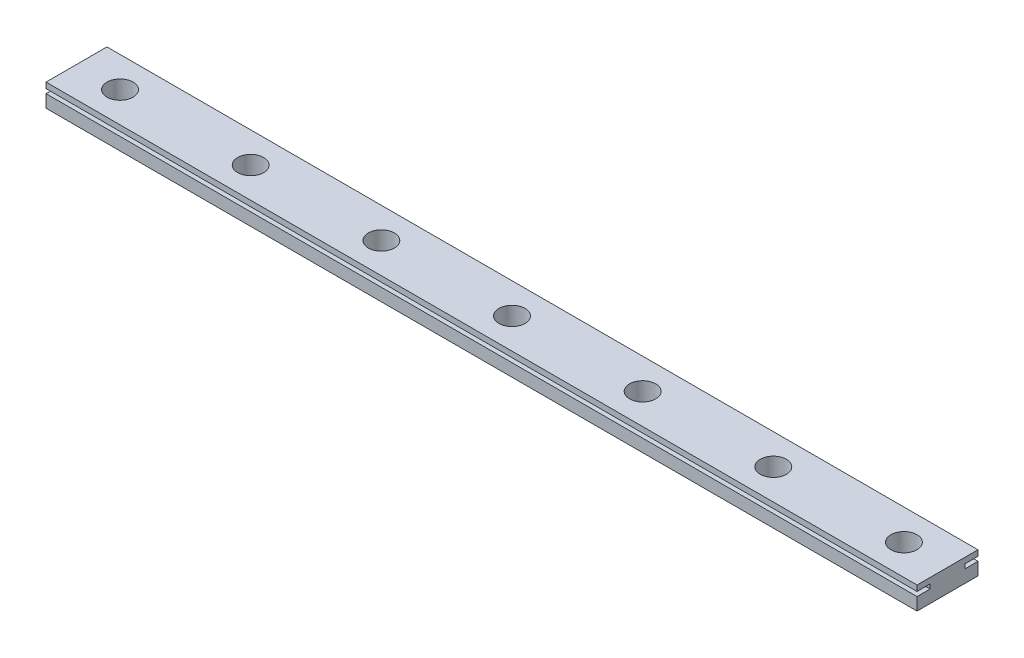
from build123d import *

# Parameters (mm, degrees)
SKETCH_1_W             = 200
SKETCH_1_H             = 14
EXTRUDE_1_DEPTH        = 5.2
SKETCH_2_W             = 3
SKETCH_2_H             = 1
CUT_EXTRUDE_1_DEPTH    = 210
SKETCH_3_R             = 1.75
CUT_EXTRUDE_2_DEPTH    = 31
SKETCH_3_3_R           = 3
SKETCH_3_3_R_2         = 1.75
CUT_EXTRUDE_3_DEPTH    = 4.5
PATTERN_LINEAR_1_COUNT = 7
PATTERN_LINEAR_1_PITCH = 30


with BuildPart() as part:
    # 草图1 → 凸台-拉伸1 (new body)
    with BuildSketch(Plane(origin=(0, 0, 0), x_dir=(1, 0, 0), z_dir=(0, 1, 0))):
        with Locations((100, 7)):
            Rectangle(SKETCH_1_W, SKETCH_1_H)
    extrude(amount=EXTRUDE_1_DEPTH)

    # 草图2 → 切除-拉伸1 (cut)
    with BuildSketch(Plane.ZY):
        with Locations((-12.5, 3.4)):
            Rectangle(SKETCH_2_W, SKETCH_2_H)
        with Locations((-1.5, 3.4)):
            Rectangle(SKETCH_2_W, SKETCH_2_H)
    extrude(amount=-CUT_EXTRUDE_1_DEPTH, mode=Mode.SUBTRACT)

    # 草图3 → 切除-拉伸2 (cut)
    with BuildSketch(Plane(origin=(0, 5.2, 0), x_dir=(1, 0, 0), z_dir=(0, 1, 0))):
        with Locations((10, 7)):
            Circle(SKETCH_3_R)
    cut_extrude_2 = extrude(amount=-CUT_EXTRUDE_2_DEPTH, mode=Mode.SUBTRACT)

    # 草图3<3> → 切除-拉伸3 (cut)
    with BuildSketch(Plane(origin=(0, 5.2, 0), x_dir=(1, 0, 0), z_dir=(0, 1, 0))):
        with Locations((10, 7)):
            Circle(SKETCH_3_3_R)
        with Locations((10, 7)):
            Circle(SKETCH_3_3_R_2, mode=Mode.SUBTRACT)
    cut_extrude_3 = extrude(amount=-CUT_EXTRUDE_3_DEPTH, mode=Mode.SUBTRACT)

    # 阵列(线性)1: 切除-拉伸2, 切除-拉伸3 ×7
    with Locations(*[(i * PATTERN_LINEAR_1_PITCH, 0, 0) for i in range(1, PATTERN_LINEAR_1_COUNT)]):
        add(cut_extrude_2, mode=Mode.SUBTRACT)
        add(cut_extrude_3, mode=Mode.SUBTRACT)


solid = part.part
